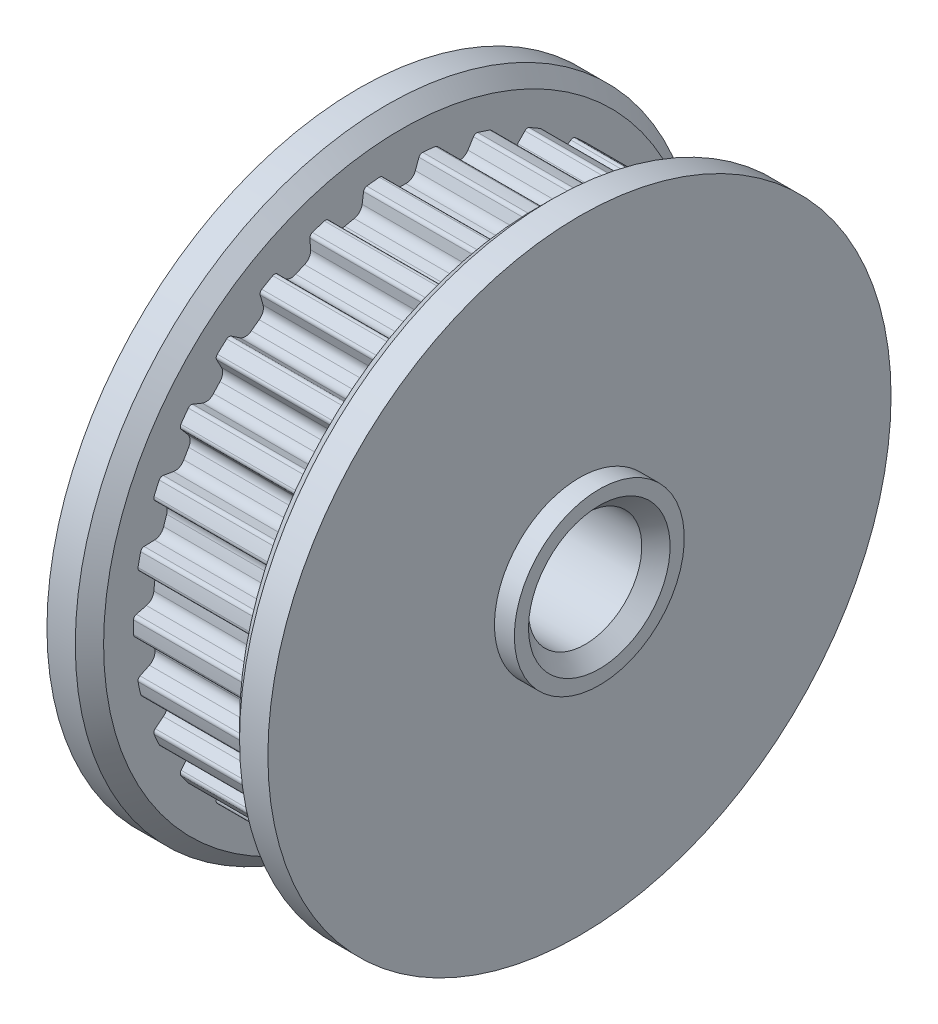
from build123d import *

# Parameters (mm, degrees)
SKETCH_7_R               = 11
SKETCH_7_R_2             = 2
EXTRUDE_1_DEPTH          = 1.5
CHAMFER_1_SIZE           = 0.5
CUT_EXTRUDE_2_REACH      = 19.059
PATTERN_CIRCULAR_3_COUNT = 30
SKETCH_8_R               = 11
SKETCH_8_R_2             = 3
EXTRUDE_2_DEPTH          = 1.5
CHAMFER_2_SIZE           = 0.5
CHAMFER_3_SIZE           = 0.5


with BuildPart() as part:
    # 草图1 → 旋转1 (revolve)
    with BuildSketch(Plane.XY, mode=Mode.PRIVATE) as revolve_1_sk:
        Polygon((0, 2), (0, 9.446), (4.8, 9.446), (4.8, 3), (7, 3), (7, 2), align=None)
    revolve(revolve_1_sk.sketch.rotate(Axis((0, 0, 0), (1, 0, 0)), 90), axis=Axis((0, 0, 0), (1, 0, 0)))

    # 草图7 → 凸台-拉伸1 (add)
    with BuildSketch(Plane.ZY):
        Circle(SKETCH_7_R)
        Circle(SKETCH_7_R_2, mode=Mode.SUBTRACT)
    extrude(amount=EXTRUDE_1_DEPTH)

    # 倒角1
    chamfer_1_edges = [part.edges().sort_by_distance(p)[0] for p in [
        (-1.5, 0, -2),
        (7, 0, -2),
    ]]
    chamfer(chamfer_1_edges, length=CHAMFER_1_SIZE)

    # 草图6 → 切除-拉伸2 (cut, up to next)
    with BuildSketch(Plane(origin=(0, 0, 0), x_dir=(0, 0, -1), z_dir=(1, 0, 0)), mode=Mode.PRIVATE) as cut_extrude_2_sk1:
        with BuildLine():
            Line((0.632530376, 9.329843514), (0.50685519, 8.984553779))
            ThreePointArc((0.50685519, 8.984553779), (0.375903219, 8.815609518), (0.171122561, 8.754327677))
            ThreePointArc((0.171122561, 8.754327677), (0, 8.756), (-0.171122561, 8.754327677))
            ThreePointArc((-0.171122561, 8.754327677), (-0.375903219, 8.815609518), (-0.50685519, 8.984553779))
            Line((-0.50685519, 8.984553779), (-0.632530376, 9.329843514))
            ThreePointArc((-0.632530376, 9.329843514), (-0.684503697, 9.394805867), (-0.765221734, 9.414953622))
            ThreePointArc((-0.765221734, 9.414953622), (-0.82998998, 9.409465056), (-0.894718924, 9.403530935))
            Line((-0.894718924, 9.403530935), (-1.392814798, 10.772038102))
            ThreePointArc((-1.392814798, 10.772038102), (0, 10.861709715), (1.392814798, 10.772038102))
            Line((1.392814798, 10.772038102), (0.894718924, 9.403530935))
            ThreePointArc((0.894718924, 9.403530935), (0.82998998, 9.409465056), (0.765221734, 9.414953622))
            ThreePointArc((0.765221734, 9.414953622), (0.684503697, 9.394805867), (0.632530376, 9.329843514))
        make_face()
    cut_extrude_2_tool1 = extrude(cut_extrude_2_sk1.sketch, amount=CUT_EXTRUDE_2_REACH, mode=Mode.PRIVATE) & part.part
    cut_extrude_2 = cut_extrude_2_tool1.solids().sort_by_distance((0, 9.990305, 0))[0]
    add(cut_extrude_2, mode=Mode.SUBTRACT)

    # 阵列(圆周)3: 切除-拉伸2 ×30 about axis
    pattern_circular_3_axis = Axis((0, 0, 0), (1, 0, 0))
    for i in range(1, PATTERN_CIRCULAR_3_COUNT):
        add(cut_extrude_2.rotate(pattern_circular_3_axis, i * 360 / PATTERN_CIRCULAR_3_COUNT), mode=Mode.SUBTRACT)

    # 倒角2
    chamfer_2_edges = [part.edges().sort_by_distance(p)[0] for p in [
        (0, 0, -11),
    ]]
    chamfer(chamfer_2_edges, length=CHAMFER_2_SIZE)


with BuildPart() as body_2:
    # 草图8 → 凸台-拉伸2 (new body)
    with BuildSketch(Plane(origin=(4.8, 0, 0), x_dir=(0, 0, -1), z_dir=(1, 0, 0))):
        Circle(SKETCH_8_R)
        Circle(SKETCH_8_R_2, mode=Mode.SUBTRACT)
    extrude(amount=EXTRUDE_2_DEPTH)

    # 倒角3
    chamfer_3_edges = [body_2.edges().sort_by_distance(p)[0] for p in [
        (4.8, 0, 11),
        (4.8, 0, 3),
    ]]
    chamfer(chamfer_3_edges, length=CHAMFER_3_SIZE)


solid = Compound([part.part, body_2.part])
